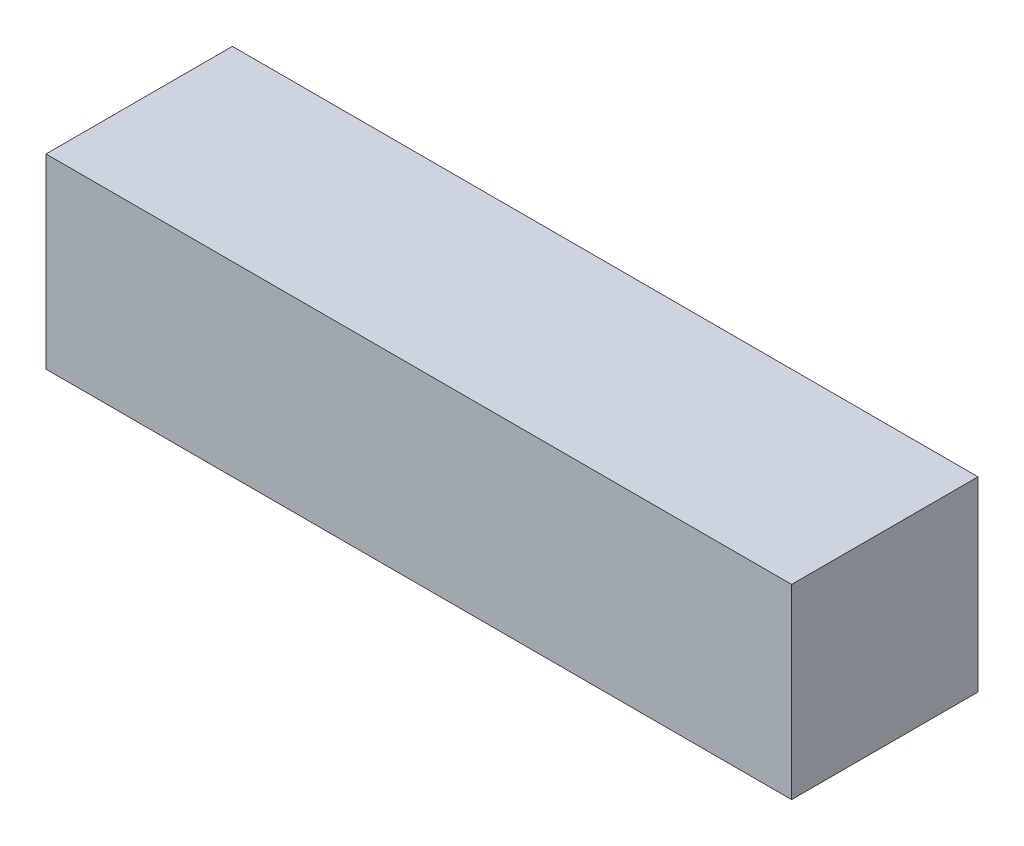
from build123d import *

# Parameters (mm, degrees)
SKETCH1_W           = 101.6
SKETCH1_H           = 25.4
BOSS_EXTRUDE1_DEPTH = 25.4


with BuildPart() as part:
    # Sketch1 → Boss-Extrude1 (new body)
    with BuildSketch(Plane.XY):
        with Locations((-15.515431773, 9.602439024)):
            Rectangle(SKETCH1_W, SKETCH1_H)
    extrude(amount=BOSS_EXTRUDE1_DEPTH)


solid = part.part
